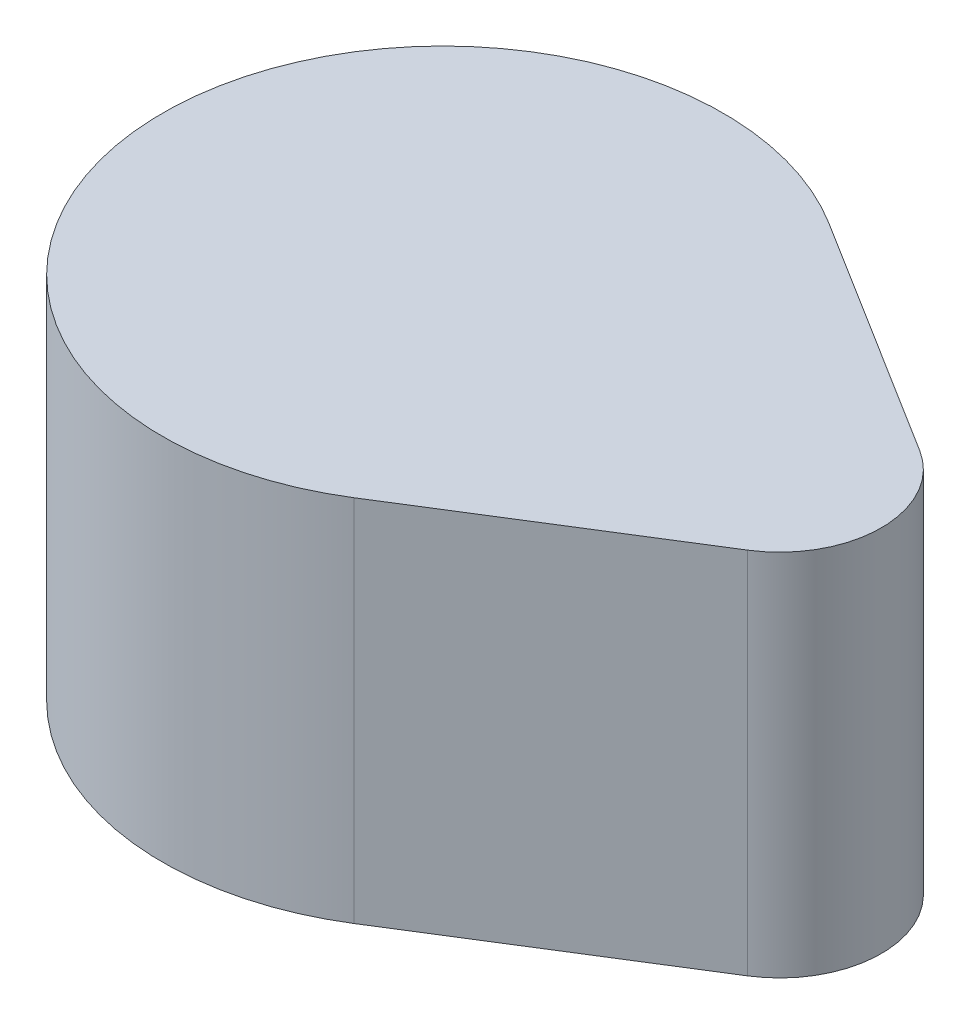
from build123d import *

# Parameters (mm, degrees)
BOSS_EXTRUDE1_DEPTH = 12.7


with BuildPart() as part:
    # Sketch1 → Boss-Extrude1 (new body)
    with BuildSketch(Plane(origin=(0, 0, 0), x_dir=(1, 0, 0), z_dir=(0, 1, 0))):
        with BuildLine():
            Line((5.116163793, 8.182137132), (13.455603448, 2.967614504))
            ThreePointArc((13.455603448, 2.967614504), (15.1, 0), (13.455603448, -2.967614504))
            Line((13.455603448, -2.967614504), (5.116163793, -8.182137132))
            ThreePointArc((5.116163793, -8.182137132), (-9.65, 0), (5.116163793, 8.182137132))
        make_face()
    extrude(amount=BOSS_EXTRUDE1_DEPTH)


solid = part.part
